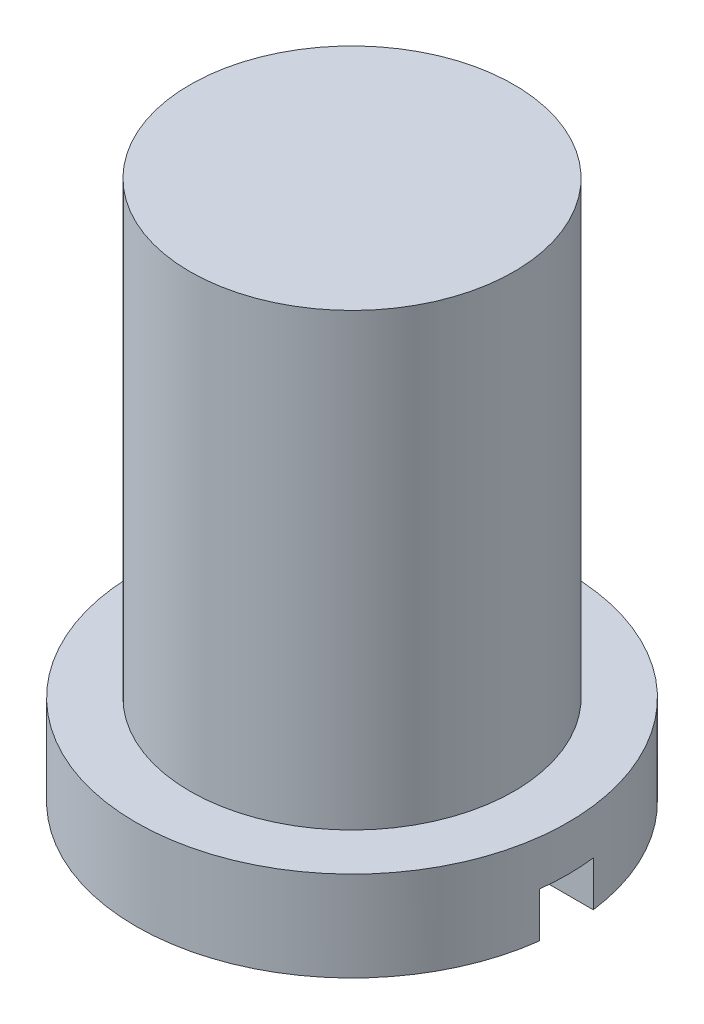
from build123d import *

# Parameters (mm, degrees)
ESQUISSE1_R             = 2.4
ESQUISSE1_R_2           = 1.8
BOSS_EXTRU_1_DEPTH      = 1
ESQUISSE2_R             = 1.8
BOSS_EXTRU_2_DEPTH      = 5
ENL_V_MAT_EXTRU_1_DEPTH = 0.5


with BuildPart() as part:
    # Esquisse1 → Boss.-Extru.1 (new body)
    with BuildSketch(Plane(origin=(0, 0, 0), x_dir=(1, 0, 0), z_dir=(0, 1, 0))):
        with Locations(Location((0, 0, 0), (0, 0, 270))):
            Circle(ESQUISSE1_R)
        Circle(ESQUISSE1_R_2, mode=Mode.SUBTRACT)
        Circle(ESQUISSE1_R_2)
    extrude(amount=BOSS_EXTRU_1_DEPTH)

    # Esquisse2 → Boss.-Extru.2 (add)
    with BuildSketch(Plane(origin=(0, 1, 0), x_dir=(1, 0, 0), z_dir=(0, 1, 0))):
        with Locations(Location((0, 0, 0), (0, 0, 270))):
            Circle(ESQUISSE2_R)
    extrude(amount=BOSS_EXTRU_2_DEPTH)

    # Esquisse3 → Enlèv. mat.-Extru.1 (cut)
    with BuildSketch(Plane.XZ):
        Polygon((2.4, 0), (2.4, -0.3), (-2.4, -0.3), (-2.4, 0), (-2.4, 0.297130131), (2.4, 0.297130131), align=None)
    extrude(amount=-ENL_V_MAT_EXTRU_1_DEPTH, mode=Mode.SUBTRACT)


solid = part.part
